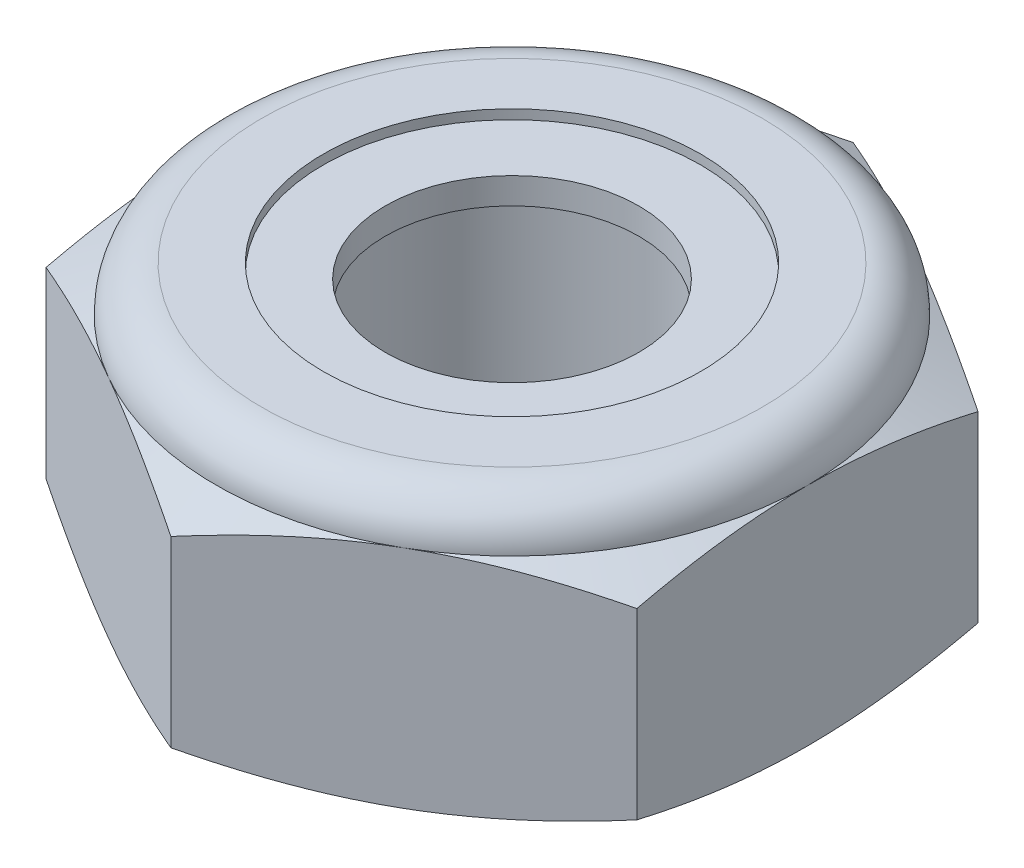
from build123d import *

# Parameters (mm, degrees)
EXTRUDE1_DEPTH = 4.365625
SKETCH2_W      = 2.413
SKETCH2_H      = 4.365625


with BuildPart() as part:
    # Sketch1 → Extrude1 (new body)
    with BuildSketch(Plane(origin=(0, 0, 0), x_dir=(1, 0, 0), z_dir=(0, 1, 0))):
        Polygon((0, 5.499261314), (-4.7625, 2.749630657), (-4.7625, -2.749630657), (0, -5.499261314), (4.7625, -2.749630657), (4.7625, 2.749630657), align=None)
    extrude(amount=EXTRUDE1_DEPTH)

    # Sketch4 → Cut-Revolve2 (revolve, cut)
    with BuildSketch(Plane(origin=(0, 0, 0), x_dir=(0, 0, -1), z_dir=(1, 0, 0))):
        Polygon((0, 4.365625), (2.413, 4.365625), (2.045424837, 4.194221887), (2.045424837, 0.171403113), (2.413, 0), (0, 0), align=None)
    revolve(axis=Axis((0, 4.365625, 0), (0, 1, 0)), mode=Mode.SUBTRACT)


with BuildPart() as body_2:
    # Sketch2 → Revolve1 (revolve)
    with BuildSketch(Plane(origin=(0, 0, 0), x_dir=(0, 0, -1), z_dir=(1, 0, 0))):
        with Locations((1.2065, 2.1828125)):
            Rectangle(SKETCH2_W, SKETCH2_H)
    revolve(axis=Axis((0, -2.413, 0), (0, 1, 0)))


with BuildPart() as part_1:
    add(part.part)

    # Combine1: cut body 2
    add(body_2.part, mode=Mode.SUBTRACT)

    # Sketch5 → Cut-Revolve3 (revolve, cut)
    with BuildSketch(Plane(origin=(0, 0, 0), x_dir=(0, 0, -1), z_dir=(1, 0, 0))):
        with BuildLine():
            Line((0, 0), (4.7625, 0))
            Line((4.7625, 0), (5.499261314, 0.343557443))
            Line((5.499261314, 0.343557443), (5.499261314, 3.29446339))
            Line((5.499261314, 3.29446339), (4.7625, 3.638020833))
            ThreePointArc((4.7625, 3.638020833), (4.549389674, 4.152514674), (4.034895833, 4.365625))
            Line((4.034895833, 4.365625), (4.034895833, 5.635625))
            Line((4.034895833, 5.635625), (6.769261314, 5.635625))
            Line((6.769261314, 5.635625), (6.769261314, -1.27))
            Line((6.769261314, -1.27), (0, -1.27))
            Line((0, -1.27), (0, 0))
        make_face()
    revolve(axis=Axis((0, 0, 0), (0, 1, 0)), mode=Mode.SUBTRACT)

    # Sketch6 → Cut-Revolve4 (revolve, cut)
    with BuildSketch(Plane(origin=(0, 0, 0), x_dir=(0, 0, -1), z_dir=(1, 0, 0))):
        with BuildLine():
            Line((0, 3.638020833), (4.6101, 3.638020833))
            ThreePointArc((4.6101, 3.638020833), (4.4416266, 4.0447516), (4.034895833, 4.213225))
            Line((4.034895833, 4.213225), (3.040160335, 4.213225))
            Line((3.040160335, 4.213225), (3.040160335, 5.635625))
            Line((3.040160335, 5.635625), (0, 5.635625))
            Line((0, 5.635625), (0, 3.638020833))
        make_face()
    revolve(axis=Axis((0, 5.635625, 0), (0, 1, 0)), mode=Mode.SUBTRACT)


with BuildPart() as body_2_2:
    # Sketch7 → Revolve2 (revolve)
    with BuildSketch(Plane(origin=(0, 0, 0), x_dir=(0, 0, -1), z_dir=(1, 0, 0))):
        with BuildLine():
            Line((2.045424837, 3.714220833), (4.528047654, 3.714220833))
            ThreePointArc((4.528047654, 3.714220833), (4.359688876, 4.016854092), (4.034895833, 4.137025))
            Line((4.034895833, 4.137025), (2.045424837, 4.137025))
            Line((2.045424837, 4.137025), (2.045424837, 3.714220833))
        make_face()
    revolve(axis=Axis((0, 3.714220833, 0), (0, 1, 0)))


solid = Compound([part_1.part, body_2_2.part])
